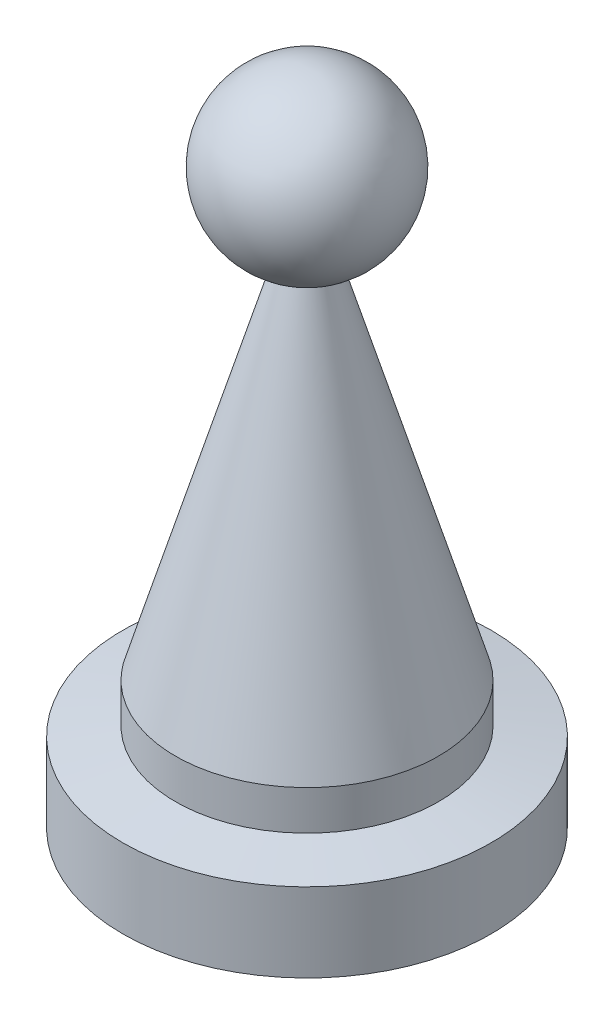
from build123d import *


with BuildPart() as part:
    # Sketch1 → Revolve1 (revolve)
    with BuildSketch(Plane.XY, mode=Mode.PRIVATE) as revolve1_sk:
        with BuildLine():
            Line((0, 0), (0, 25))
            ThreePointArc((0, 25), (3.216433228, 22.215894078), (0.922164426, 18.633573718))
            Line((0.922164426, 18.633573718), (5, 4.852653961))
            Line((5, 4.852653961), (5, 3.352653961))
            Line((5, 3.352653961), (7, 3))
            Line((7, 3), (7, 0))
            Line((7, 0), (0, 0))
        make_face()
    revolve(revolve1_sk.sketch.rotate(Axis((0, 0, 0), (0, 1, 0)), 90), axis=Axis((0, 0, 0), (0, 1, 0)))  # turned: the seam where the file's is


solid = part.part
